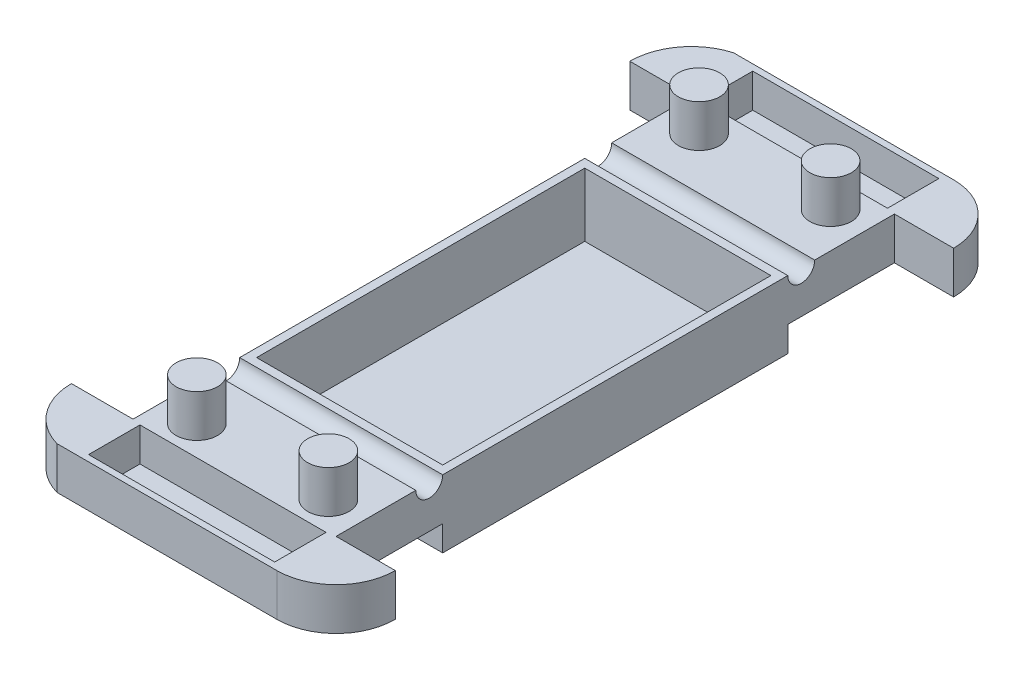
from build123d import *

# Parameters (mm, degrees)
BOSS_EXTRUDE1_DEPTH     = 12.7
SKETCH3_R               = 4.039553008
CUT_EXTRUDE1_DEPTH      = 80.451479119
SKETCH4_R               = 6.227777938
BOSS_EXTRUDE3_DEPTH     = 12.7
SKETCH5_W               = 55.88
SKETCH5_H               = 98.530771833
CUT_EXTRUDE2_DEPTH      = 13.7
CUT_EXTRUDE2_DEPTH_BACK = 13.7
SKETCH6_W               = 55.88
SKETCH6_H               = 15.424799931
CUT_EXTRUDE3_DEPTH      = 10.16
SKETCH7_W               = 60.96
SKETCH7_H               = 103.610771833
BOSS_EXTRUDE4_DEPTH     = 7.62
SKETCH8_W               = 55.88
SKETCH8_H               = 98.530771833
CUT_EXTRUDE4_DEPTH      = 6.35


with BuildPart() as part:
    # Sketch1 → Boss-Extrude1 (new body)
    with BuildSketch(Plane(origin=(0, 0, 0), x_dir=(1, 0, 0), z_dir=(0, 1, 0))):
        with BuildLine():
            Line((-24.894407518, 17.78), (41.145592482, 17.78))
            ThreePointArc((41.145592482, 17.78), (53.717951052, 12.572358569), (58.925592482, 0))
            Line((58.925592482, 0), (41.145592482, 0))
            Line((41.145592482, 0), (41.145592482, -167.64))
            Line((41.145592482, -167.64), (58.925592482, -167.64))
            ThreePointArc((58.925592482, -167.64), (53.717951052, -180.212358569), (41.145592482, -185.42))
            Line((41.145592482, -185.42), (-24.894407518, -185.42))
            ThreePointArc((-24.894407518, -185.42), (-34.577054874, -178.775485757), (-38.305886636, -167.64))
            Line((-38.305886636, -167.64), (-19.814407518, -167.64))
            Line((-19.814407518, -167.64), (-19.814407518, 0))
            Line((-19.814407518, 0), (-38.305886636, 0))
            ThreePointArc((-38.305886636, 0), (-34.577054874, 11.135485757), (-24.894407518, 17.78))
        make_face()
    extrude(amount=BOSS_EXTRUDE1_DEPTH)

    # Sketch3 → Cut-Extrude1 (cut, through all)
    with BuildSketch(Plane(origin=(41.145592482, 0, 0), x_dir=(0, 0, -1), z_dir=(1, 0, 0))):
        with Locations((-139.663754312, 12.7)):
            Circle(SKETCH3_R)
        with Locations((-27.973876463, 12.7)):
            Circle(SKETCH3_R)
    extrude(amount=-CUT_EXTRUDE1_DEPTH, mode=Mode.SUBTRACT)

    # Sketch4 → Boss-Extrude3 (add)
    with BuildSketch(Plane(origin=(0, 12.7, 0), x_dir=(1, 0, 0), z_dir=(0, 1, 0))):
        with Locations((30.41662766, -8.42802752)):
            Circle(SKETCH4_R)
        with Locations((30.41662766, -159.21197248)):
            Circle(SKETCH4_R)
        with Locations((-9.085442695, -159.21197248)):
            Circle(SKETCH4_R)
        with Locations((-9.085442695, -8.42802752)):
            Circle(SKETCH4_R)
    extrude(amount=BOSS_EXTRUDE3_DEPTH)

    # Sketch5 → Cut-Extrude2 (cut, two sides)
    with BuildSketch(Plane(origin=(0, 12.7, 0), x_dir=(1, 0, 0), z_dir=(0, 1, 0))) as cut_extrude2_sk:
        with Locations((10.665592482, -83.818815387)):
            Rectangle(SKETCH5_W, SKETCH5_H)
    extrude(amount=CUT_EXTRUDE2_DEPTH, mode=Mode.SUBTRACT)
    extrude(cut_extrude2_sk.sketch, amount=-CUT_EXTRUDE2_DEPTH_BACK, mode=Mode.SUBTRACT)

    # Sketch6 → Cut-Extrude3 (cut)
    with BuildSketch(Plane(origin=(0, 12.7, 0), x_dir=(1, 0, 0), z_dir=(0, 1, 0))):
        with Locations((10.665592482, -175.814372445)):
            Rectangle(SKETCH6_W, SKETCH6_H)
        with Locations((10.665592482, 8.174372446)):
            Rectangle(SKETCH6_W, SKETCH6_H)
    extrude(amount=-CUT_EXTRUDE3_DEPTH, mode=Mode.SUBTRACT)

    # Sketch7 → Boss-Extrude4 (add)
    with BuildSketch(Plane.XZ):
        with Locations((10.665592482, 83.818815387)):
            Rectangle(SKETCH7_W, SKETCH7_H)
    extrude(amount=BOSS_EXTRUDE4_DEPTH)

    # Sketch8 → Cut-Extrude4 (cut, symmetric)
    with BuildSketch(Plane(origin=(0, 0, 0), x_dir=(1, 0, 0), z_dir=(0, 1, 0))):
        with Locations((10.665592482, -83.818815387)):
            Rectangle(SKETCH8_W, SKETCH8_H)
    extrude(amount=CUT_EXTRUDE4_DEPTH, both=True, mode=Mode.SUBTRACT)


solid = part.part
